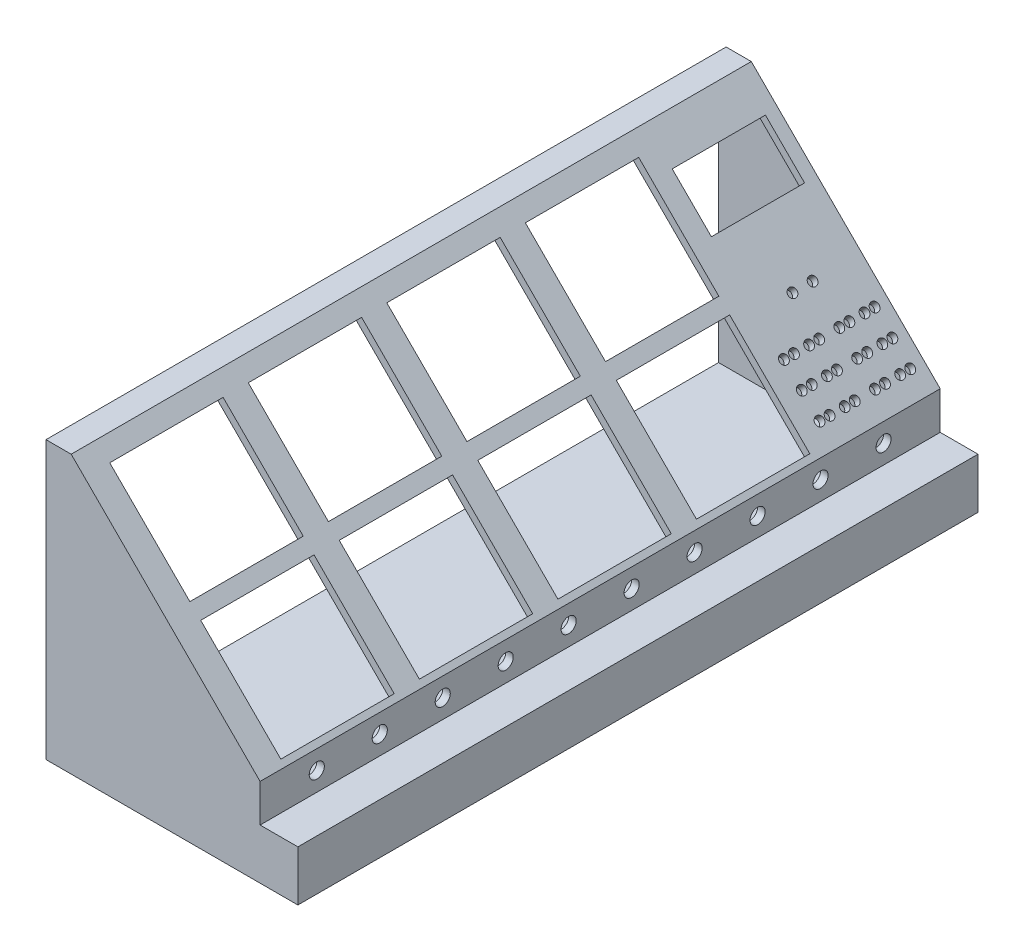
from build123d import *

# Parameters (mm, degrees)
EXTRUDE_1_DEPTH     = 270
SHELL_6_T           = -3
SKETCH_8_W          = 45
SKETCH_8_H          = 45
CUT_EXTRUDE_1_DEPTH = 300.677004987
SKETCH_8_5_R        = 1.75
SKETCH_8_5_W        = 45
SKETCH_8_5_H        = 45
SKETCH_8_5_W_2      = 37
SKETCH_8_5_H_2      = 22
CUT_EXTRUDE_3_DEPTH = 10
SKETCH_10_R         = 3
CUT_EXTRUDE_4_DEPTH = 3
SKETCH_15_R         = 1.5
CUT_EXTRUDE_5_DEPTH = 3


with BuildPart() as part:
    # 草图1 → 凸台-拉伸1 (new body)
    with BuildSketch(Plane.XY):
        Polygon((-93.609952443, -20), (6.390047557, -20), (6.390047557, 0), (-8.609952443, 0), (-8.609952443, 15), (-83.609952443, 90), (-93.609952443, 90), align=None)
    extrude(amount=EXTRUDE_1_DEPTH)

    # 抽壳6
    shell_6_openings = [part.faces().sort_by_distance(p)[0] for p in [
        (-93.609952443, 35, 135),
    ]]
    offset(amount=SHELL_6_T, openings=shell_6_openings, kind=Kind.INTERSECTION)

    # 草图8 → 切除-拉伸1 (cut, through all)
    with BuildSketch(Plane(origin=(3.195023779, 3.195023779, 0), x_dir=(0, 0, -1), z_dir=(0.7071067811865481, 0.7071067811865469, 0))):
        with Locations((-237.5, 92.760774654)):
            Rectangle(SKETCH_8_W, SKETCH_8_H)
    extrude(amount=-CUT_EXTRUDE_1_DEPTH, mode=Mode.SUBTRACT)

    # 草图8<5> → 切除-拉伸3 (cut)
    with BuildSketch(Plane(origin=(3.195023779, 3.195023779, 0), x_dir=(0, 0, -1), z_dir=(0.7071067811865481, 0.7071067811865469, 0))):
        with Locations((-19.5, 45.760774654)):
            Circle(SKETCH_8_5_R)
        with Locations((-15.5, 45.760774654)):
            Circle(SKETCH_8_5_R)
        with Locations((-9.5, 45.760774654)):
            Circle(SKETCH_8_5_R)
        with Locations((-5.5, 45.760774654)):
            Circle(SKETCH_8_5_R)
        with Locations((-27.5, 45.760774654)):
            Circle(SKETCH_8_5_R)
        with Locations((-31.5, 45.760774654)):
            Circle(SKETCH_8_5_R)
        with Locations((-37.5, 45.760774654)):
            Circle(SKETCH_8_5_R)
        with Locations((-41.5, 45.760774654)):
            Circle(SKETCH_8_5_R)
        with Locations((-5.5, 35.760774654)):
            Circle(SKETCH_8_5_R)
        with Locations((-9.5, 35.760774654)):
            Circle(SKETCH_8_5_R)
        with Locations((-15.5, 35.760774654)):
            Circle(SKETCH_8_5_R)
        with Locations((-19.5, 35.760774654)):
            Circle(SKETCH_8_5_R)
        with Locations((-27.5, 35.760774654)):
            Circle(SKETCH_8_5_R)
        with Locations((-31.5, 35.760774654)):
            Circle(SKETCH_8_5_R)
        with Locations((-37.5, 35.760774654)):
            Circle(SKETCH_8_5_R)
        with Locations((-41.5, 35.760774654)):
            Circle(SKETCH_8_5_R)
        with Locations((-41.5, 25.760774654)):
            Circle(SKETCH_8_5_R)
        with Locations((-37.5, 25.760774654)):
            Circle(SKETCH_8_5_R)
        with Locations((-31.5, 25.760774654)):
            Circle(SKETCH_8_5_R)
        with Locations((-27.5, 25.760774654)):
            Circle(SKETCH_8_5_R)
        with Locations((-19.5, 25.760774654)):
            Circle(SKETCH_8_5_R)
        with Locations((-15.5, 25.760774654)):
            Circle(SKETCH_8_5_R)
        with Locations((-9.5, 25.760774654)):
            Circle(SKETCH_8_5_R)
        with Locations((-5.5, 25.760774654)):
            Circle(SKETCH_8_5_R)
        with Locations((-19.5, 60.760774654)):
            Circle(SKETCH_8_5_R)
        with Locations((-27.5, 60.760774654)):
            Circle(SKETCH_8_5_R)
        with Locations((-237.5, 41.694757476)):
            Rectangle(SKETCH_8_5_W, SKETCH_8_5_H)
        with Locations((-237.5, 92.760774654)):
            Rectangle(SKETCH_8_5_W, SKETCH_8_5_H)
        with Locations((-182.5, 92.760774654)):
            Rectangle(SKETCH_8_5_W, SKETCH_8_5_H)
        with Locations((-127.5, 92.760774654)):
            Rectangle(SKETCH_8_5_W, SKETCH_8_5_H)
        with Locations((-182.5, 41.694757476)):
            Rectangle(SKETCH_8_5_W, SKETCH_8_5_H)
        with Locations((-72.5, 92.760774654)):
            Rectangle(SKETCH_8_5_W, SKETCH_8_5_H)
        with Locations((-127.5, 41.694757476)):
            Rectangle(SKETCH_8_5_W, SKETCH_8_5_H)
        with Locations((-72.5, 41.694757476)):
            Rectangle(SKETCH_8_5_W, SKETCH_8_5_H)
        with Locations((-23.5, 96.760774654)):
            Rectangle(SKETCH_8_5_W_2, SKETCH_8_5_H_2)
    extrude(amount=-CUT_EXTRUDE_3_DEPTH, mode=Mode.SUBTRACT)

    # 草图10 → 切除-拉伸4 (cut)
    with BuildSketch(Plane(origin=(-8.609952443, 0, 0), x_dir=(0, 0, -1), z_dir=(1, 0, 0))):
        with Locations((-247.5, 7.5)):
            Circle(SKETCH_10_R)
        with Locations((-222.5, 7.5)):
            Circle(SKETCH_10_R)
        with Locations((-97.5, 7.5)):
            Circle(SKETCH_10_R)
        with Locations((-122.5, 7.5)):
            Circle(SKETCH_10_R)
        with Locations((-147.5, 7.5)):
            Circle(SKETCH_10_R)
        with Locations((-172.5, 7.5)):
            Circle(SKETCH_10_R)
        with Locations((-197.5, 7.5)):
            Circle(SKETCH_10_R)
        with Locations((-72.5, 7.5)):
            Circle(SKETCH_10_R)
        with Locations((-47.5, 7.5)):
            Circle(SKETCH_10_R)
        with Locations((-22.5, 7.5)):
            Circle(SKETCH_10_R)
    extrude(amount=-CUT_EXTRUDE_4_DEPTH, mode=Mode.SUBTRACT)

    # 草图15 → 切除-拉伸5 (cut)
    with BuildSketch(Plane.XZ.offset(20)):
        with Locations((-31.109952443, 192.5)):
            Circle(SKETCH_15_R)
        with Locations((-13.609952443, 192.5)):
            Circle(SKETCH_15_R)
        with Locations((-3.609952443, 240)):
            Circle(SKETCH_15_R)
        with Locations((-31.109952443, 240)):
            Circle(SKETCH_15_R)
    extrude(amount=-CUT_EXTRUDE_5_DEPTH, mode=Mode.SUBTRACT)


solid = part.part
